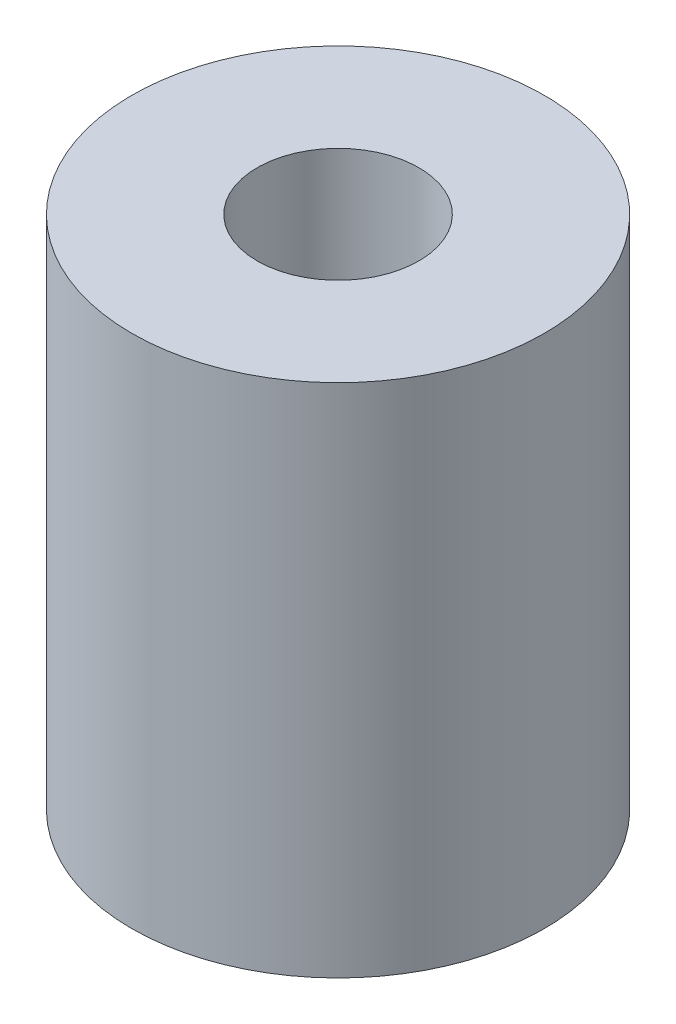
from build123d import *

# Parameters (mm, degrees)
SKETCH1_R           = 6.35
SKETCH1_R_2         = 2.4892
BOSS_EXTRUDE1_DEPTH = 15.875


with BuildPart() as part:
    # Sketch1 → Boss-Extrude1 (new body)
    with BuildSketch(Plane(origin=(0, 0, 0), x_dir=(1, 0, 0), z_dir=(0, 1, 0))):
        Circle(SKETCH1_R)
        Circle(SKETCH1_R_2, mode=Mode.SUBTRACT)
    extrude(amount=BOSS_EXTRUDE1_DEPTH)


solid = part.part
